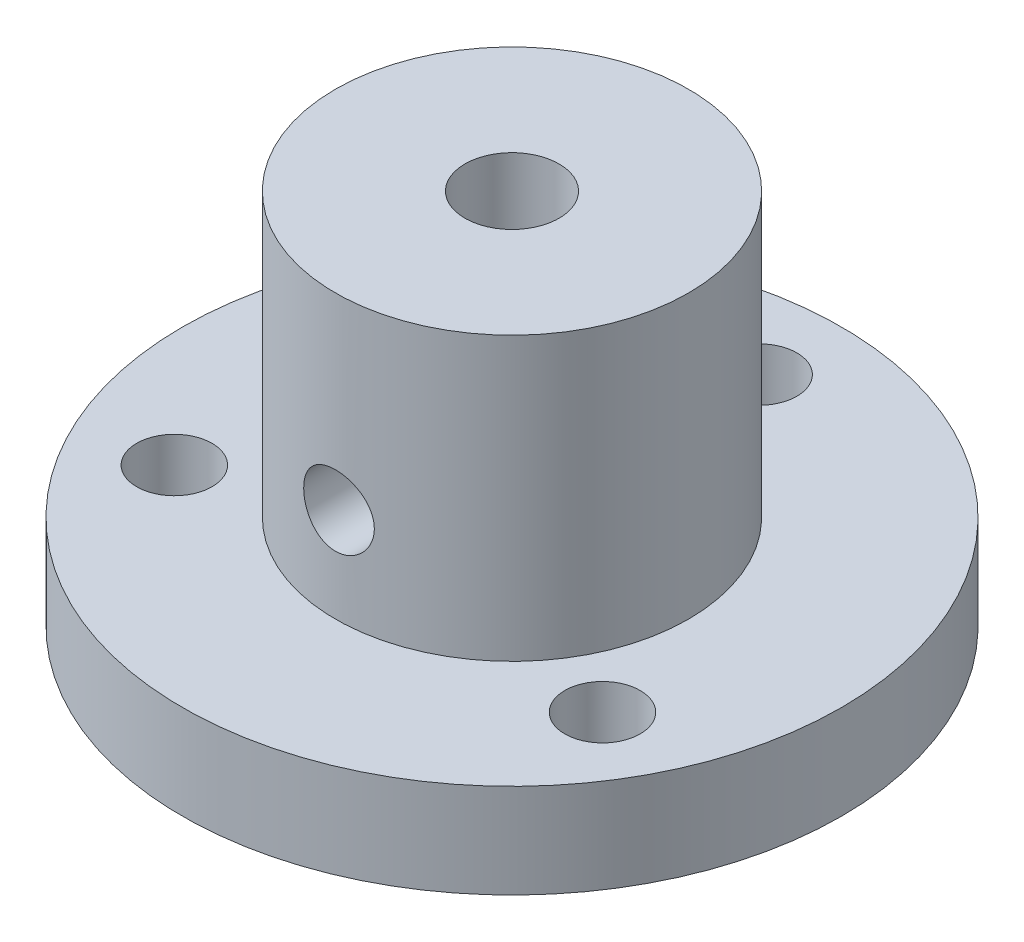
from build123d import *

# Parameters (mm, degrees)
SKETCH2_R          = 1.6
CUT_EXTRUDE1_DEPTH = 17
SKETCH3_R          = 1.5
CUT_EXTRUDE2_DEPTH = 15


with BuildPart() as part:
    # Sketch1 → Revolve1 (revolve)
    with BuildSketch(Plane.XY):
        Polygon((-14, 0), (-14, 4), (-7.5, 4), (-7.5, 16), (-2, 16), (-2, 0), align=None)
    revolve(axis=Axis((0, 0, 0), (0, -1, 0)))

    # Sketch2 → Cut-Extrude1 (cut, through all)
    with BuildSketch(Plane(origin=(0, 0, 0), x_dir=(1, 0, 0), z_dir=(0, 1, 0))):
        with Locations((0, 10.5)):
            Circle(SKETCH2_R)
        with Locations((9.09326674, -5.25)):
            Circle(SKETCH2_R)
        with Locations((-9.09326674, -5.25)):
            Circle(SKETCH2_R)
    extrude(amount=CUT_EXTRUDE1_DEPTH, mode=Mode.SUBTRACT)

    # Sketch3 → Cut-Extrude2 (cut, through all)
    with BuildSketch(Plane.XY):
        with Locations((0, 8)):
            Circle(SKETCH3_R)
    extrude(amount=CUT_EXTRUDE2_DEPTH, mode=Mode.SUBTRACT)


solid = part.part
